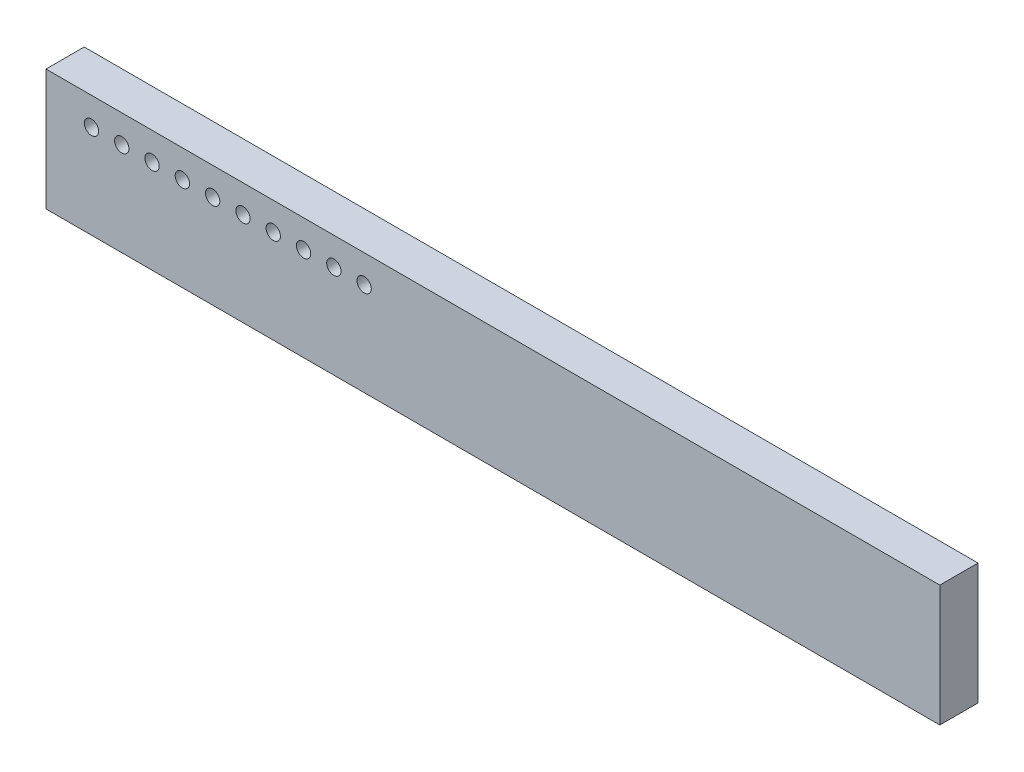
from build123d import *

# Parameters (mm, degrees)
SKETCH1_W           = 37.465
SKETCH1_H           = 5.08
BOSS_EXTRUDE1_DEPTH = 1.6
SKETCH2_R           = 0.3
CUT_EXTRUDE1_DEPTH  = 2.54


with BuildPart() as part:
    # Sketch1 → Boss-Extrude1 (new body)
    with BuildSketch(Plane.XY):
        Rectangle(SKETCH1_W, SKETCH1_H)
    extrude(amount=BOSS_EXTRUDE1_DEPTH)

    # Sketch2 → Cut-Extrude1 (cut)
    with BuildSketch(Plane.XY.offset(1.6)):
        with Locations((-5.3975, 1.38)):
            Circle(SKETCH2_R)
        with Locations((-6.6675, 1.38)):
            Circle(SKETCH2_R)
        with Locations((-7.9375, 1.38)):
            Circle(SKETCH2_R)
        with Locations((-9.2075, 1.38)):
            Circle(SKETCH2_R)
        with Locations((-10.4775, 1.38)):
            Circle(SKETCH2_R)
        with Locations((-11.7475, 1.38)):
            Circle(SKETCH2_R)
        with Locations((-13.0175, 1.38)):
            Circle(SKETCH2_R)
        with Locations((-14.2875, 1.38)):
            Circle(SKETCH2_R)
        with Locations((-15.5575, 1.38)):
            Circle(SKETCH2_R)
        with Locations((-16.8275, 1.38)):
            Circle(SKETCH2_R)
    extrude(amount=-CUT_EXTRUDE1_DEPTH, mode=Mode.SUBTRACT)


solid = part.part
